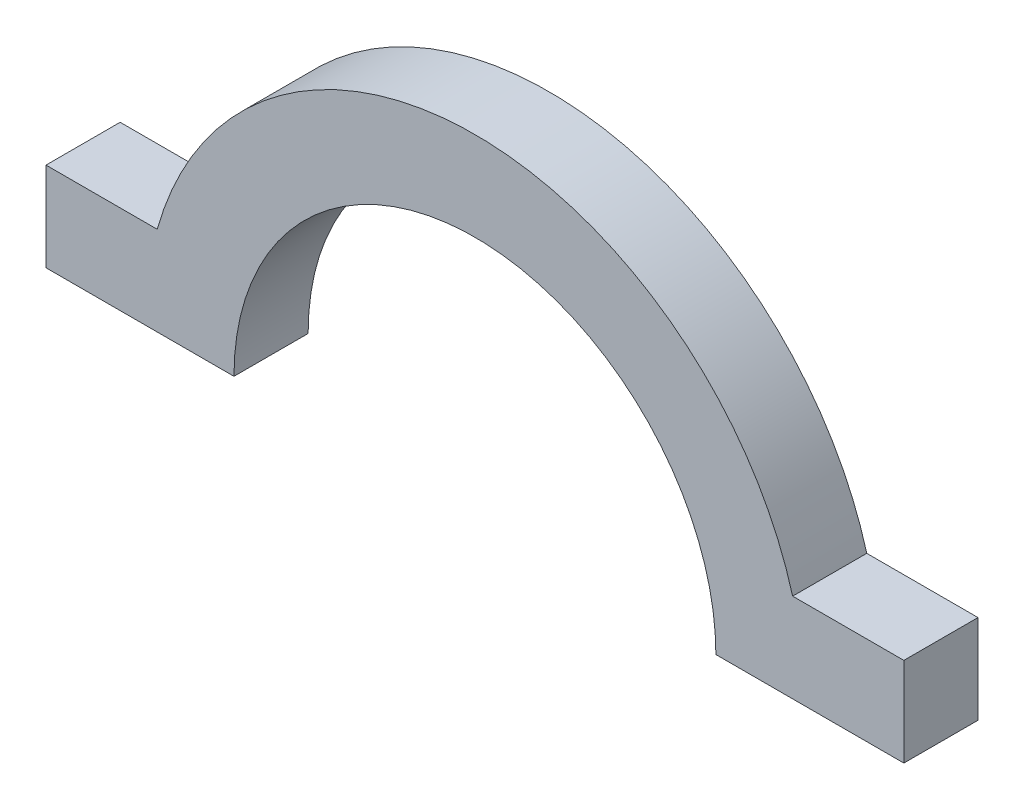
from build123d import *

# Parameters (mm, degrees)
BOSS_EXTRUDE1_DEPTH = 10


with BuildPart() as part:
    # Sketch1 → Boss-Extrude1 (new body)
    with BuildSketch(Plane.XY):
        with BuildLine():
            Line((-32.5, 0), (-57.851487722, 0))
            Line((-57.851487722, 0), (-57.851487722, 12))
            Line((-57.851487722, 12), (-42.851487722, 12))
            ThreePointArc((-42.851487722, 12), (0, 44.5), (42.851487722, 12))
            Line((42.851487722, 12), (57.851487722, 12))
            Line((57.851487722, 12), (57.851487722, 0))
            Line((57.851487722, 0), (32.5, 0))
            ThreePointArc((32.5, 0), (0, 32.5), (-32.5, 0))
        make_face()
    extrude(amount=BOSS_EXTRUDE1_DEPTH)


solid = part.part
